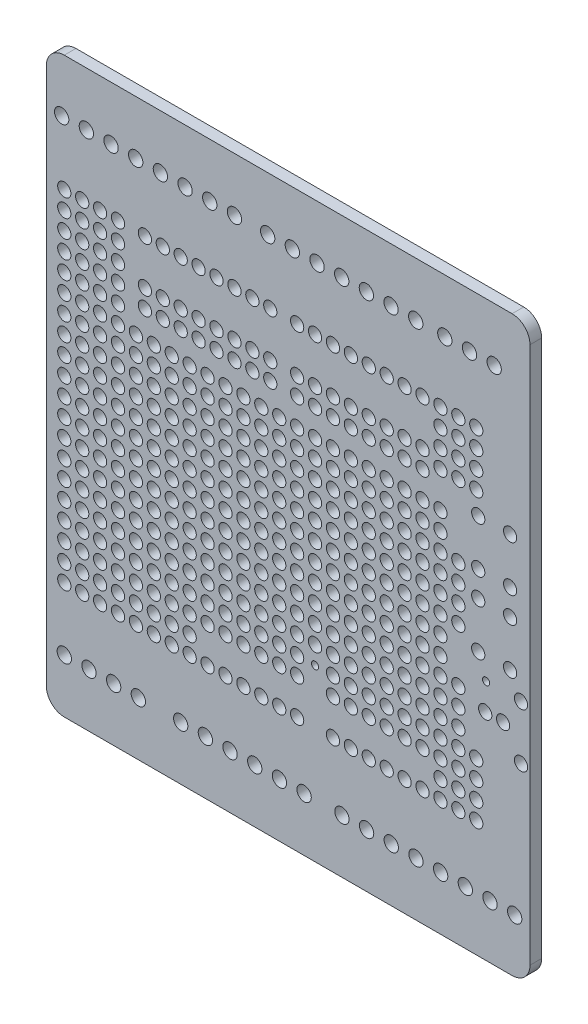
from build123d import *

# Parameters (mm, degrees)
MODEL_R             = 1.016
MODEL_R_2           = 0.9398
MODEL_R_3           = 0.508
BOSS_EXTRUDE1_DEPTH = 1.651


with BuildPart() as part:
    # Model → Boss-Extrude1 (new body)
    with BuildSketch(Plane.XY):
        with BuildLine():
            Line((2.54, 0), (66.04, 0))
            ThreePointArc((66.04, 0), (67.836051224, 0.743948776), (68.58, 2.54))
            Line((68.58, 2.54), (68.58, 78.74))
            ThreePointArc((68.58, 78.74), (67.836051224, 80.536051224), (66.04, 81.28))
            Line((66.04, 81.28), (2.54, 81.28))
            ThreePointArc((2.54, 81.28), (0.743948776, 80.536051224), (0, 78.74))
            Line((0, 78.74), (0, 2.54))
            ThreePointArc((0, 2.54), (0.743948776, 0.743948776), (2.54, 0))
        make_face()
        with Locations((45.409993, 7.62)):
            Circle(MODEL_R, mode=Mode.SUBTRACT)
        with Locations((48.9100114, 7.62)):
            Circle(MODEL_R, mode=Mode.SUBTRACT)
        with Locations((52.4100044, 7.62)):
            Circle(MODEL_R, mode=Mode.SUBTRACT)
        with Locations((55.9099974, 7.62)):
            Circle(MODEL_R, mode=Mode.SUBTRACT)
        with Locations((59.4099904, 7.62)):
            Circle(MODEL_R, mode=Mode.SUBTRACT)
        with Locations((62.9100088, 7.62)):
            Circle(MODEL_R, mode=Mode.SUBTRACT)
        with Locations((66.4100018, 7.62)):
            Circle(MODEL_R, mode=Mode.SUBTRACT)
        with Locations((22.549993, 7.62)):
            Circle(MODEL_R, mode=Mode.SUBTRACT)
        with Locations((26.0500114, 7.62)):
            Circle(MODEL_R, mode=Mode.SUBTRACT)
        with Locations((29.5500044, 7.62)):
            Circle(MODEL_R, mode=Mode.SUBTRACT)
        with Locations((33.0499974, 7.62)):
            Circle(MODEL_R, mode=Mode.SUBTRACT)
        with Locations((36.5499904, 7.62)):
            Circle(MODEL_R, mode=Mode.SUBTRACT)
        with Locations((6.039993, 7.62)):
            Circle(MODEL_R, mode=Mode.SUBTRACT)
        with Locations((9.5400114, 7.62)):
            Circle(MODEL_R, mode=Mode.SUBTRACT)
        with Locations((13.0400044, 7.62)):
            Circle(MODEL_R, mode=Mode.SUBTRACT)
        with Locations((52.380007, 73.66)):
            Circle(MODEL_R, mode=Mode.SUBTRACT)
        with Locations((48.8799886, 73.66)):
            Circle(MODEL_R, mode=Mode.SUBTRACT)
        with Locations((45.3799956, 73.66)):
            Circle(MODEL_R, mode=Mode.SUBTRACT)
        with Locations((41.8800026, 73.66)):
            Circle(MODEL_R, mode=Mode.SUBTRACT)
        with Locations((38.3800096, 73.66)):
            Circle(MODEL_R, mode=Mode.SUBTRACT)
        with Locations((34.8799912, 73.66)):
            Circle(MODEL_R, mode=Mode.SUBTRACT)
        with Locations((31.3799982, 73.66)):
            Circle(MODEL_R, mode=Mode.SUBTRACT)
        with Locations((23.170007, 73.66)):
            Circle(MODEL_R, mode=Mode.SUBTRACT)
        with Locations((19.6699886, 73.66)):
            Circle(MODEL_R, mode=Mode.SUBTRACT)
        with Locations((16.1699956, 73.66)):
            Circle(MODEL_R, mode=Mode.SUBTRACT)
        with Locations((12.6700026, 73.66)):
            Circle(MODEL_R, mode=Mode.SUBTRACT)
        with Locations((9.1700096, 73.66)):
            Circle(MODEL_R, mode=Mode.SUBTRACT)
        with Locations((5.6699912, 73.66)):
            Circle(MODEL_R, mode=Mode.SUBTRACT)
        with Locations((2.1699982, 73.66)):
            Circle(MODEL_R, mode=Mode.SUBTRACT)
        with Locations((60.000007, 73.66)):
            Circle(MODEL_R, mode=Mode.SUBTRACT)
        with Locations((62.23, 30.48)):
            Circle(MODEL_R_2, mode=Mode.SUBTRACT)
        with Locations((64.77, 30.48)):
            Circle(MODEL_R_2, mode=Mode.SUBTRACT)
        with Locations((67.31, 26.67)):
            Circle(MODEL_R_2, mode=Mode.SUBTRACT)
        with Locations((67.31, 34.29)):
            Circle(MODEL_R_2, mode=Mode.SUBTRACT)
        with Locations((65.7606, 43.8912)):
            Circle(MODEL_R_2, mode=Mode.SUBTRACT)
        with Locations((65.7606, 37.3888)):
            Circle(MODEL_R_2, mode=Mode.SUBTRACT)
        with Locations((61.2394, 43.8912)):
            Circle(MODEL_R_2, mode=Mode.SUBTRACT)
        with Locations((61.2394, 37.3888)):
            Circle(MODEL_R_2, mode=Mode.SUBTRACT)
        with Locations((65.7606, 54.0512)):
            Circle(MODEL_R_2, mode=Mode.SUBTRACT)
        with Locations((65.7606, 47.5488)):
            Circle(MODEL_R_2, mode=Mode.SUBTRACT)
        with Locations((61.2394, 54.0512)):
            Circle(MODEL_R_2, mode=Mode.SUBTRACT)
        with Locations((61.2394, 47.5488)):
            Circle(MODEL_R_2, mode=Mode.SUBTRACT)
        with Locations((25.4, 16.51)):
            Circle(MODEL_R_2, mode=Mode.SUBTRACT)
        with Locations((27.94, 16.51)):
            Circle(MODEL_R_2, mode=Mode.SUBTRACT)
        with Locations((40.64, 16.51)):
            Circle(MODEL_R_2, mode=Mode.SUBTRACT)
        with Locations((43.18, 16.51)):
            Circle(MODEL_R_2, mode=Mode.SUBTRACT)
        with Locations((45.72, 16.51)):
            Circle(MODEL_R_2, mode=Mode.SUBTRACT)
        with Locations((48.26, 16.51)):
            Circle(MODEL_R_2, mode=Mode.SUBTRACT)
        with Locations((50.8, 16.51)):
            Circle(MODEL_R_2, mode=Mode.SUBTRACT)
        with Locations((53.34, 16.51)):
            Circle(MODEL_R_2, mode=Mode.SUBTRACT)
        with Locations((13.97, 64.77)):
            Circle(MODEL_R_2, mode=Mode.SUBTRACT)
        with Locations((48.26, 64.77)):
            Circle(MODEL_R_2, mode=Mode.SUBTRACT)
        with Locations((45.72, 64.77)):
            Circle(MODEL_R_2, mode=Mode.SUBTRACT)
        with Locations((43.18, 64.77)):
            Circle(MODEL_R_2, mode=Mode.SUBTRACT)
        with Locations((40.64, 64.77)):
            Circle(MODEL_R_2, mode=Mode.SUBTRACT)
        with Locations((38.1, 64.77)):
            Circle(MODEL_R_2, mode=Mode.SUBTRACT)
        with Locations((35.56, 64.77)):
            Circle(MODEL_R_2, mode=Mode.SUBTRACT)
        with Locations((31.75, 64.77)):
            Circle(MODEL_R_2, mode=Mode.SUBTRACT)
        with Locations((29.21, 64.77)):
            Circle(MODEL_R_2, mode=Mode.SUBTRACT)
        with Locations((26.67, 64.77)):
            Circle(MODEL_R_2, mode=Mode.SUBTRACT)
        with Locations((24.13, 64.77)):
            Circle(MODEL_R_2, mode=Mode.SUBTRACT)
        with Locations((21.59, 64.77)):
            Circle(MODEL_R_2, mode=Mode.SUBTRACT)
        with Locations((19.05, 64.77)):
            Circle(MODEL_R_2, mode=Mode.SUBTRACT)
        with Locations((30.48, 16.51)):
            Circle(MODEL_R_2, mode=Mode.SUBTRACT)
        with Locations((33.02, 16.51)):
            Circle(MODEL_R_2, mode=Mode.SUBTRACT)
        with Locations((16.51, 64.77)):
            Circle(MODEL_R_2, mode=Mode.SUBTRACT)
        with Locations((22.86, 16.51)):
            Circle(MODEL_R_2, mode=Mode.SUBTRACT)
        with Locations((53.34, 64.77)):
            Circle(MODEL_R_2, mode=Mode.SUBTRACT)
        with Locations((50.8, 64.77)):
            Circle(MODEL_R_2, mode=Mode.SUBTRACT)
        with Locations((35.56, 16.51)):
            Circle(MODEL_R_2, mode=Mode.SUBTRACT)
        with Locations((25.4, 24.13)):
            Circle(MODEL_R_2, mode=Mode.SUBTRACT)
        with Locations((25.4, 21.59)):
            Circle(MODEL_R_2, mode=Mode.SUBTRACT)
        with Locations((45.72, 34.29)):
            Circle(MODEL_R_2, mode=Mode.SUBTRACT)
        with Locations((48.26, 34.29)):
            Circle(MODEL_R_2, mode=Mode.SUBTRACT)
        with Locations((50.8, 34.29)):
            Circle(MODEL_R_2, mode=Mode.SUBTRACT)
        with Locations((53.34, 34.29)):
            Circle(MODEL_R_2, mode=Mode.SUBTRACT)
        with Locations((55.88, 34.29)):
            Circle(MODEL_R_2, mode=Mode.SUBTRACT)
        with Locations((43.18, 34.29)):
            Circle(MODEL_R_2, mode=Mode.SUBTRACT)
        with Locations((40.64, 34.29)):
            Circle(MODEL_R_2, mode=Mode.SUBTRACT)
        with Locations((38.1, 34.29)):
            Circle(MODEL_R_2, mode=Mode.SUBTRACT)
        with Locations((35.56, 34.29)):
            Circle(MODEL_R_2, mode=Mode.SUBTRACT)
        with Locations((33.02, 34.29)):
            Circle(MODEL_R_2, mode=Mode.SUBTRACT)
        with Locations((30.48, 34.29)):
            Circle(MODEL_R_2, mode=Mode.SUBTRACT)
        with Locations((27.94, 34.29)):
            Circle(MODEL_R_2, mode=Mode.SUBTRACT)
        with Locations((25.4, 34.29)):
            Circle(MODEL_R_2, mode=Mode.SUBTRACT)
        with Locations((22.86, 34.29)):
            Circle(MODEL_R_2, mode=Mode.SUBTRACT)
        with Locations((17.78, 34.29)):
            Circle(MODEL_R_2, mode=Mode.SUBTRACT)
        with Locations((20.32, 34.29)):
            Circle(MODEL_R_2, mode=Mode.SUBTRACT)
        with Locations((27.94, 24.13)):
            Circle(MODEL_R_2, mode=Mode.SUBTRACT)
        with Locations((45.72, 49.53)):
            Circle(MODEL_R_2, mode=Mode.SUBTRACT)
        with Locations((48.26, 49.53)):
            Circle(MODEL_R_2, mode=Mode.SUBTRACT)
        with Locations((50.8, 49.53)):
            Circle(MODEL_R_2, mode=Mode.SUBTRACT)
        with Locations((53.34, 49.53)):
            Circle(MODEL_R_2, mode=Mode.SUBTRACT)
        with Locations((55.88, 49.53)):
            Circle(MODEL_R_2, mode=Mode.SUBTRACT)
        with Locations((43.18, 49.53)):
            Circle(MODEL_R_2, mode=Mode.SUBTRACT)
        with Locations((40.64, 49.53)):
            Circle(MODEL_R_2, mode=Mode.SUBTRACT)
        with Locations((38.1, 49.53)):
            Circle(MODEL_R_2, mode=Mode.SUBTRACT)
        with Locations((35.56, 49.53)):
            Circle(MODEL_R_2, mode=Mode.SUBTRACT)
        with Locations((33.02, 49.53)):
            Circle(MODEL_R_2, mode=Mode.SUBTRACT)
        with Locations((30.48, 49.53)):
            Circle(MODEL_R_2, mode=Mode.SUBTRACT)
        with Locations((27.94, 49.53)):
            Circle(MODEL_R_2, mode=Mode.SUBTRACT)
        with Locations((25.4, 49.53)):
            Circle(MODEL_R_2, mode=Mode.SUBTRACT)
        with Locations((22.86, 49.53)):
            Circle(MODEL_R_2, mode=Mode.SUBTRACT)
        with Locations((17.78, 49.53)):
            Circle(MODEL_R_2, mode=Mode.SUBTRACT)
        with Locations((20.32, 49.53)):
            Circle(MODEL_R_2, mode=Mode.SUBTRACT)
        with Locations((15.24, 49.53)):
            Circle(MODEL_R_2, mode=Mode.SUBTRACT)
        with Locations((12.7, 49.53)):
            Circle(MODEL_R_2, mode=Mode.SUBTRACT)
        with Locations((10.16, 49.53)):
            Circle(MODEL_R_2, mode=Mode.SUBTRACT)
        with Locations((7.62, 49.53)):
            Circle(MODEL_R_2, mode=Mode.SUBTRACT)
        with Locations((5.08, 49.53)):
            Circle(MODEL_R_2, mode=Mode.SUBTRACT)
        with Locations((2.54, 49.53)):
            Circle(MODEL_R_2, mode=Mode.SUBTRACT)
        with Locations((27.94, 21.59)):
            Circle(MODEL_R_2, mode=Mode.SUBTRACT)
        with Locations((40.64, 21.59)):
            Circle(MODEL_R_2, mode=Mode.SUBTRACT)
        with Locations((40.64, 24.13)):
            Circle(MODEL_R_2, mode=Mode.SUBTRACT)
        with Locations((43.18, 24.13)):
            Circle(MODEL_R_2, mode=Mode.SUBTRACT)
        with Locations((43.18, 21.59)):
            Circle(MODEL_R_2, mode=Mode.SUBTRACT)
        with Locations((45.72, 21.59)):
            Circle(MODEL_R_2, mode=Mode.SUBTRACT)
        with Locations((45.72, 24.13)):
            Circle(MODEL_R_2, mode=Mode.SUBTRACT)
        with Locations((48.26, 24.13)):
            Circle(MODEL_R_2, mode=Mode.SUBTRACT)
        with Locations((48.26, 21.59)):
            Circle(MODEL_R_2, mode=Mode.SUBTRACT)
        with Locations((50.8, 24.13)):
            Circle(MODEL_R_2, mode=Mode.SUBTRACT)
        with Locations((50.8, 21.59)):
            Circle(MODEL_R_2, mode=Mode.SUBTRACT)
        with Locations((53.34, 24.13)):
            Circle(MODEL_R_2, mode=Mode.SUBTRACT)
        with Locations((53.34, 21.59)):
            Circle(MODEL_R_2, mode=Mode.SUBTRACT)
        with Locations((13.97, 55.88)):
            Circle(MODEL_R_2, mode=Mode.SUBTRACT)
        with Locations((13.97, 58.42)):
            Circle(MODEL_R_2, mode=Mode.SUBTRACT)
        with Locations((5.08, 29.21)):
            Circle(MODEL_R_2, mode=Mode.SUBTRACT)
        with Locations((5.08, 31.75)):
            Circle(MODEL_R_2, mode=Mode.SUBTRACT)
        with Locations((5.08, 26.67)):
            Circle(MODEL_R_2, mode=Mode.SUBTRACT)
        with Locations((7.62, 31.75)):
            Circle(MODEL_R_2, mode=Mode.SUBTRACT)
        with Locations((7.62, 26.67)):
            Circle(MODEL_R_2, mode=Mode.SUBTRACT)
        with Locations((7.62, 29.21)):
            Circle(MODEL_R_2, mode=Mode.SUBTRACT)
        with Locations((10.16, 29.21)):
            Circle(MODEL_R_2, mode=Mode.SUBTRACT)
        with Locations((10.16, 31.75)):
            Circle(MODEL_R_2, mode=Mode.SUBTRACT)
        with Locations((10.16, 26.67)):
            Circle(MODEL_R_2, mode=Mode.SUBTRACT)
        with Locations((12.7, 31.75)):
            Circle(MODEL_R_2, mode=Mode.SUBTRACT)
        with Locations((12.7, 29.21)):
            Circle(MODEL_R_2, mode=Mode.SUBTRACT)
        with Locations((12.7, 26.67)):
            Circle(MODEL_R_2, mode=Mode.SUBTRACT)
        with Locations((15.24, 26.67)):
            Circle(MODEL_R_2, mode=Mode.SUBTRACT)
        with Locations((15.24, 29.21)):
            Circle(MODEL_R_2, mode=Mode.SUBTRACT)
        with Locations((15.24, 31.75)):
            Circle(MODEL_R_2, mode=Mode.SUBTRACT)
        with Locations((17.78, 26.67)):
            Circle(MODEL_R_2, mode=Mode.SUBTRACT)
        with Locations((17.78, 29.21)):
            Circle(MODEL_R_2, mode=Mode.SUBTRACT)
        with Locations((17.78, 31.75)):
            Circle(MODEL_R_2, mode=Mode.SUBTRACT)
        with Locations((20.32, 26.67)):
            Circle(MODEL_R_2, mode=Mode.SUBTRACT)
        with Locations((20.32, 29.21)):
            Circle(MODEL_R_2, mode=Mode.SUBTRACT)
        with Locations((20.32, 31.75)):
            Circle(MODEL_R_2, mode=Mode.SUBTRACT)
        with Locations((22.86, 26.67)):
            Circle(MODEL_R_2, mode=Mode.SUBTRACT)
        with Locations((22.86, 29.21)):
            Circle(MODEL_R_2, mode=Mode.SUBTRACT)
        with Locations((22.86, 31.75)):
            Circle(MODEL_R_2, mode=Mode.SUBTRACT)
        with Locations((25.4, 26.67)):
            Circle(MODEL_R_2, mode=Mode.SUBTRACT)
        with Locations((25.4, 29.21)):
            Circle(MODEL_R_2, mode=Mode.SUBTRACT)
        with Locations((25.4, 31.75)):
            Circle(MODEL_R_2, mode=Mode.SUBTRACT)
        with Locations((27.94, 26.67)):
            Circle(MODEL_R_2, mode=Mode.SUBTRACT)
        with Locations((27.94, 29.21)):
            Circle(MODEL_R_2, mode=Mode.SUBTRACT)
        with Locations((27.94, 31.75)):
            Circle(MODEL_R_2, mode=Mode.SUBTRACT)
        with Locations((30.48, 26.67)):
            Circle(MODEL_R_2, mode=Mode.SUBTRACT)
        with Locations((30.48, 29.21)):
            Circle(MODEL_R_2, mode=Mode.SUBTRACT)
        with Locations((30.48, 31.75)):
            Circle(MODEL_R_2, mode=Mode.SUBTRACT)
        with Locations((33.02, 26.67)):
            Circle(MODEL_R_2, mode=Mode.SUBTRACT)
        with Locations((33.02, 29.21)):
            Circle(MODEL_R_2, mode=Mode.SUBTRACT)
        with Locations((33.02, 31.75)):
            Circle(MODEL_R_2, mode=Mode.SUBTRACT)
        with Locations((35.56, 26.67)):
            Circle(MODEL_R_2, mode=Mode.SUBTRACT)
        with Locations((35.56, 29.21)):
            Circle(MODEL_R_2, mode=Mode.SUBTRACT)
        with Locations((35.56, 31.75)):
            Circle(MODEL_R_2, mode=Mode.SUBTRACT)
        with Locations((38.1, 26.67)):
            Circle(MODEL_R_2, mode=Mode.SUBTRACT)
        with Locations((38.1, 29.21)):
            Circle(MODEL_R_2, mode=Mode.SUBTRACT)
        with Locations((38.1, 31.75)):
            Circle(MODEL_R_2, mode=Mode.SUBTRACT)
        with Locations((40.64, 26.67)):
            Circle(MODEL_R_2, mode=Mode.SUBTRACT)
        with Locations((40.64, 29.21)):
            Circle(MODEL_R_2, mode=Mode.SUBTRACT)
        with Locations((40.64, 31.75)):
            Circle(MODEL_R_2, mode=Mode.SUBTRACT)
        with Locations((43.18, 26.67)):
            Circle(MODEL_R_2, mode=Mode.SUBTRACT)
        with Locations((43.18, 29.21)):
            Circle(MODEL_R_2, mode=Mode.SUBTRACT)
        with Locations((43.18, 31.75)):
            Circle(MODEL_R_2, mode=Mode.SUBTRACT)
        with Locations((45.72, 26.67)):
            Circle(MODEL_R_2, mode=Mode.SUBTRACT)
        with Locations((45.72, 29.21)):
            Circle(MODEL_R_2, mode=Mode.SUBTRACT)
        with Locations((45.72, 31.75)):
            Circle(MODEL_R_2, mode=Mode.SUBTRACT)
        with Locations((48.26, 26.67)):
            Circle(MODEL_R_2, mode=Mode.SUBTRACT)
        with Locations((48.26, 29.21)):
            Circle(MODEL_R_2, mode=Mode.SUBTRACT)
        with Locations((48.26, 31.75)):
            Circle(MODEL_R_2, mode=Mode.SUBTRACT)
        with Locations((50.8, 26.67)):
            Circle(MODEL_R_2, mode=Mode.SUBTRACT)
        with Locations((50.8, 29.21)):
            Circle(MODEL_R_2, mode=Mode.SUBTRACT)
        with Locations((50.8, 31.75)):
            Circle(MODEL_R_2, mode=Mode.SUBTRACT)
        with Locations((53.34, 26.67)):
            Circle(MODEL_R_2, mode=Mode.SUBTRACT)
        with Locations((53.34, 29.21)):
            Circle(MODEL_R_2, mode=Mode.SUBTRACT)
        with Locations((53.34, 31.75)):
            Circle(MODEL_R_2, mode=Mode.SUBTRACT)
        with Locations((55.88, 29.21)):
            Circle(MODEL_R_2, mode=Mode.SUBTRACT)
        with Locations((15.24, 46.99)):
            Circle(MODEL_R_2, mode=Mode.SUBTRACT)
        with Locations((12.7, 46.99)):
            Circle(MODEL_R_2, mode=Mode.SUBTRACT)
        with Locations((15.24, 44.45)):
            Circle(MODEL_R_2, mode=Mode.SUBTRACT)
        with Locations((15.24, 41.91)):
            Circle(MODEL_R_2, mode=Mode.SUBTRACT)
        with Locations((12.7, 44.45)):
            Circle(MODEL_R_2, mode=Mode.SUBTRACT)
        with Locations((10.16, 46.99)):
            Circle(MODEL_R_2, mode=Mode.SUBTRACT)
        with Locations((7.62, 46.99)):
            Circle(MODEL_R_2, mode=Mode.SUBTRACT)
        with Locations((10.16, 44.45)):
            Circle(MODEL_R_2, mode=Mode.SUBTRACT)
        with Locations((12.7, 41.91)):
            Circle(MODEL_R_2, mode=Mode.SUBTRACT)
        with Locations((15.24, 39.37)):
            Circle(MODEL_R_2, mode=Mode.SUBTRACT)
        with Locations((15.24, 36.83)):
            Circle(MODEL_R_2, mode=Mode.SUBTRACT)
        with Locations((12.7, 39.37)):
            Circle(MODEL_R_2, mode=Mode.SUBTRACT)
        with Locations((10.16, 41.91)):
            Circle(MODEL_R_2, mode=Mode.SUBTRACT)
        with Locations((7.62, 44.45)):
            Circle(MODEL_R_2, mode=Mode.SUBTRACT)
        with Locations((5.08, 46.99)):
            Circle(MODEL_R_2, mode=Mode.SUBTRACT)
        with Locations((2.54, 46.99)):
            Circle(MODEL_R_2, mode=Mode.SUBTRACT)
        with Locations((5.08, 44.45)):
            Circle(MODEL_R_2, mode=Mode.SUBTRACT)
        with Locations((7.62, 41.91)):
            Circle(MODEL_R_2, mode=Mode.SUBTRACT)
        with Locations((10.16, 39.37)):
            Circle(MODEL_R_2, mode=Mode.SUBTRACT)
        with Locations((12.7, 36.83)):
            Circle(MODEL_R_2, mode=Mode.SUBTRACT)
        with Locations((15.24, 34.29)):
            Circle(MODEL_R_2, mode=Mode.SUBTRACT)
        with Locations((12.7, 34.29)):
            Circle(MODEL_R_2, mode=Mode.SUBTRACT)
        with Locations((10.16, 36.83)):
            Circle(MODEL_R_2, mode=Mode.SUBTRACT)
        with Locations((7.62, 39.37)):
            Circle(MODEL_R_2, mode=Mode.SUBTRACT)
        with Locations((2.54, 44.45)):
            Circle(MODEL_R_2, mode=Mode.SUBTRACT)
        with Locations((5.08, 41.91)):
            Circle(MODEL_R_2, mode=Mode.SUBTRACT)
        with Locations((2.54, 41.91)):
            Circle(MODEL_R_2, mode=Mode.SUBTRACT)
        with Locations((5.08, 39.37)):
            Circle(MODEL_R_2, mode=Mode.SUBTRACT)
        with Locations((7.62, 36.83)):
            Circle(MODEL_R_2, mode=Mode.SUBTRACT)
        with Locations((10.16, 34.29)):
            Circle(MODEL_R_2, mode=Mode.SUBTRACT)
        with Locations((7.62, 34.29)):
            Circle(MODEL_R_2, mode=Mode.SUBTRACT)
        with Locations((2.54, 39.37)):
            Circle(MODEL_R_2, mode=Mode.SUBTRACT)
        with Locations((5.08, 36.83)):
            Circle(MODEL_R_2, mode=Mode.SUBTRACT)
        with Locations((2.54, 36.83)):
            Circle(MODEL_R_2, mode=Mode.SUBTRACT)
        with Locations((5.08, 34.29)):
            Circle(MODEL_R_2, mode=Mode.SUBTRACT)
        with Locations((2.54, 34.29)):
            Circle(MODEL_R_2, mode=Mode.SUBTRACT)
        with Locations((53.34, 58.42)):
            Circle(MODEL_R_2, mode=Mode.SUBTRACT)
        with Locations((53.34, 55.88)):
            Circle(MODEL_R_2, mode=Mode.SUBTRACT)
        with Locations((50.8, 58.42)):
            Circle(MODEL_R_2, mode=Mode.SUBTRACT)
        with Locations((50.8, 55.88)):
            Circle(MODEL_R_2, mode=Mode.SUBTRACT)
        with Locations((48.26, 58.42)):
            Circle(MODEL_R_2, mode=Mode.SUBTRACT)
        with Locations((48.26, 55.88)):
            Circle(MODEL_R_2, mode=Mode.SUBTRACT)
        with Locations((45.72, 58.42)):
            Circle(MODEL_R_2, mode=Mode.SUBTRACT)
        with Locations((45.72, 55.88)):
            Circle(MODEL_R_2, mode=Mode.SUBTRACT)
        with Locations((43.18, 58.42)):
            Circle(MODEL_R_2, mode=Mode.SUBTRACT)
        with Locations((43.18, 55.88)):
            Circle(MODEL_R_2, mode=Mode.SUBTRACT)
        with Locations((40.64, 58.42)):
            Circle(MODEL_R_2, mode=Mode.SUBTRACT)
        with Locations((40.64, 55.88)):
            Circle(MODEL_R_2, mode=Mode.SUBTRACT)
        with Locations((38.1, 58.42)):
            Circle(MODEL_R_2, mode=Mode.SUBTRACT)
        with Locations((38.1, 55.88)):
            Circle(MODEL_R_2, mode=Mode.SUBTRACT)
        with Locations((35.56, 58.42)):
            Circle(MODEL_R_2, mode=Mode.SUBTRACT)
        with Locations((35.56, 55.88)):
            Circle(MODEL_R_2, mode=Mode.SUBTRACT)
        with Locations((31.75, 58.42)):
            Circle(MODEL_R_2, mode=Mode.SUBTRACT)
        with Locations((31.75, 55.88)):
            Circle(MODEL_R_2, mode=Mode.SUBTRACT)
        with Locations((29.21, 58.42)):
            Circle(MODEL_R_2, mode=Mode.SUBTRACT)
        with Locations((29.21, 55.88)):
            Circle(MODEL_R_2, mode=Mode.SUBTRACT)
        with Locations((26.67, 58.42)):
            Circle(MODEL_R_2, mode=Mode.SUBTRACT)
        with Locations((26.67, 55.88)):
            Circle(MODEL_R_2, mode=Mode.SUBTRACT)
        with Locations((24.13, 58.42)):
            Circle(MODEL_R_2, mode=Mode.SUBTRACT)
        with Locations((24.13, 55.88)):
            Circle(MODEL_R_2, mode=Mode.SUBTRACT)
        with Locations((21.59, 58.42)):
            Circle(MODEL_R_2, mode=Mode.SUBTRACT)
        with Locations((21.59, 55.88)):
            Circle(MODEL_R_2, mode=Mode.SUBTRACT)
        with Locations((19.05, 58.42)):
            Circle(MODEL_R_2, mode=Mode.SUBTRACT)
        with Locations((19.05, 55.88)):
            Circle(MODEL_R_2, mode=Mode.SUBTRACT)
        with Locations((16.51, 58.42)):
            Circle(MODEL_R_2, mode=Mode.SUBTRACT)
        with Locations((16.51, 55.88)):
            Circle(MODEL_R_2, mode=Mode.SUBTRACT)
        with Locations((33.02, 24.13)):
            Circle(MODEL_R_2, mode=Mode.SUBTRACT)
        with Locations((55.88, 52.07)):
            Circle(MODEL_R_2, mode=Mode.SUBTRACT)
        with Locations((53.34, 52.07)):
            Circle(MODEL_R_2, mode=Mode.SUBTRACT)
        with Locations((50.8, 52.07)):
            Circle(MODEL_R_2, mode=Mode.SUBTRACT)
        with Locations((48.26, 52.07)):
            Circle(MODEL_R_2, mode=Mode.SUBTRACT)
        with Locations((45.72, 52.07)):
            Circle(MODEL_R_2, mode=Mode.SUBTRACT)
        with Locations((43.18, 52.07)):
            Circle(MODEL_R_2, mode=Mode.SUBTRACT)
        with Locations((40.64, 52.07)):
            Circle(MODEL_R_2, mode=Mode.SUBTRACT)
        with Locations((38.1, 52.07)):
            Circle(MODEL_R_2, mode=Mode.SUBTRACT)
        with Locations((35.56, 52.07)):
            Circle(MODEL_R_2, mode=Mode.SUBTRACT)
        with Locations((33.02, 52.07)):
            Circle(MODEL_R_2, mode=Mode.SUBTRACT)
        with Locations((30.48, 52.07)):
            Circle(MODEL_R_2, mode=Mode.SUBTRACT)
        with Locations((27.94, 52.07)):
            Circle(MODEL_R_2, mode=Mode.SUBTRACT)
        with Locations((25.4, 52.07)):
            Circle(MODEL_R_2, mode=Mode.SUBTRACT)
        with Locations((22.86, 52.07)):
            Circle(MODEL_R_2, mode=Mode.SUBTRACT)
        with Locations((20.32, 52.07)):
            Circle(MODEL_R_2, mode=Mode.SUBTRACT)
        with Locations((17.78, 52.07)):
            Circle(MODEL_R_2, mode=Mode.SUBTRACT)
        with Locations((15.24, 52.07)):
            Circle(MODEL_R_2, mode=Mode.SUBTRACT)
        with Locations((12.7, 52.07)):
            Circle(MODEL_R_2, mode=Mode.SUBTRACT)
        with Locations((10.16, 52.07)):
            Circle(MODEL_R_2, mode=Mode.SUBTRACT)
        with Locations((7.62, 52.07)):
            Circle(MODEL_R_2, mode=Mode.SUBTRACT)
        with Locations((5.08, 52.07)):
            Circle(MODEL_R_2, mode=Mode.SUBTRACT)
        with Locations((2.54, 52.07)):
            Circle(MODEL_R_2, mode=Mode.SUBTRACT)
        with Locations((30.48, 21.59)):
            Circle(MODEL_R_2, mode=Mode.SUBTRACT)
        with Locations((30.48, 24.13)):
            Circle(MODEL_R_2, mode=Mode.SUBTRACT)
        with Locations((33.02, 21.59)):
            Circle(MODEL_R_2, mode=Mode.SUBTRACT)
        with Locations((55.88, 36.83)):
            Circle(MODEL_R_2, mode=Mode.SUBTRACT)
        with Locations((53.34, 36.83)):
            Circle(MODEL_R_2, mode=Mode.SUBTRACT)
        with Locations((50.8, 36.83)):
            Circle(MODEL_R_2, mode=Mode.SUBTRACT)
        with Locations((48.26, 36.83)):
            Circle(MODEL_R_2, mode=Mode.SUBTRACT)
        with Locations((45.72, 36.83)):
            Circle(MODEL_R_2, mode=Mode.SUBTRACT)
        with Locations((43.18, 36.83)):
            Circle(MODEL_R_2, mode=Mode.SUBTRACT)
        with Locations((40.64, 36.83)):
            Circle(MODEL_R_2, mode=Mode.SUBTRACT)
        with Locations((38.1, 36.83)):
            Circle(MODEL_R_2, mode=Mode.SUBTRACT)
        with Locations((35.56, 36.83)):
            Circle(MODEL_R_2, mode=Mode.SUBTRACT)
        with Locations((33.02, 36.83)):
            Circle(MODEL_R_2, mode=Mode.SUBTRACT)
        with Locations((30.48, 36.83)):
            Circle(MODEL_R_2, mode=Mode.SUBTRACT)
        with Locations((27.94, 36.83)):
            Circle(MODEL_R_2, mode=Mode.SUBTRACT)
        with Locations((25.4, 36.83)):
            Circle(MODEL_R_2, mode=Mode.SUBTRACT)
        with Locations((22.86, 36.83)):
            Circle(MODEL_R_2, mode=Mode.SUBTRACT)
        with Locations((20.32, 36.83)):
            Circle(MODEL_R_2, mode=Mode.SUBTRACT)
        with Locations((17.78, 36.83)):
            Circle(MODEL_R_2, mode=Mode.SUBTRACT)
        with Locations((55.88, 31.75)):
            Circle(MODEL_R_2, mode=Mode.SUBTRACT)
        with Locations((55.88, 26.67)):
            Circle(MODEL_R_2, mode=Mode.SUBTRACT)
        with Locations((2.54, 16.51)):
            Circle(MODEL_R_2, mode=Mode.SUBTRACT)
        with Locations((2.54, 19.05)):
            Circle(MODEL_R_2, mode=Mode.SUBTRACT)
        with Locations((2.54, 24.13)):
            Circle(MODEL_R_2, mode=Mode.SUBTRACT)
        with Locations((2.54, 21.59)):
            Circle(MODEL_R_2, mode=Mode.SUBTRACT)
        with Locations((5.08, 24.13)):
            Circle(MODEL_R_2, mode=Mode.SUBTRACT)
        with Locations((5.08, 59.69)):
            Circle(MODEL_R_2, mode=Mode.SUBTRACT)
        with Locations((5.08, 57.15)):
            Circle(MODEL_R_2, mode=Mode.SUBTRACT)
        with Locations((7.62, 57.15)):
            Circle(MODEL_R_2, mode=Mode.SUBTRACT)
        with Locations((7.62, 59.69)):
            Circle(MODEL_R_2, mode=Mode.SUBTRACT)
        with Locations((10.16, 59.69)):
            Circle(MODEL_R_2, mode=Mode.SUBTRACT)
        with Locations((10.16, 57.15)):
            Circle(MODEL_R_2, mode=Mode.SUBTRACT)
        with Locations((7.62, 24.13)):
            Circle(MODEL_R_2, mode=Mode.SUBTRACT)
        with Locations((10.16, 24.13)):
            Circle(MODEL_R_2, mode=Mode.SUBTRACT)
        with Locations((12.7, 24.13)):
            Circle(MODEL_R_2, mode=Mode.SUBTRACT)
        with Locations((15.24, 24.13)):
            Circle(MODEL_R_2, mode=Mode.SUBTRACT)
        with Locations((17.78, 24.13)):
            Circle(MODEL_R_2, mode=Mode.SUBTRACT)
        with Locations((20.32, 24.13)):
            Circle(MODEL_R_2, mode=Mode.SUBTRACT)
        with Locations((5.08, 21.59)):
            Circle(MODEL_R_2, mode=Mode.SUBTRACT)
        with Locations((7.62, 21.59)):
            Circle(MODEL_R_2, mode=Mode.SUBTRACT)
        with Locations((10.16, 21.59)):
            Circle(MODEL_R_2, mode=Mode.SUBTRACT)
        with Locations((12.7, 21.59)):
            Circle(MODEL_R_2, mode=Mode.SUBTRACT)
        with Locations((15.24, 21.59)):
            Circle(MODEL_R_2, mode=Mode.SUBTRACT)
        with Locations((17.78, 21.59)):
            Circle(MODEL_R_2, mode=Mode.SUBTRACT)
        with Locations((20.32, 21.59)):
            Circle(MODEL_R_2, mode=Mode.SUBTRACT)
        with Locations((55.88, 24.13)):
            Circle(MODEL_R_2, mode=Mode.SUBTRACT)
        with Locations((58.42, 24.13)):
            Circle(MODEL_R_2, mode=Mode.SUBTRACT)
        with Locations((60.96, 24.13)):
            Circle(MODEL_R_2, mode=Mode.SUBTRACT)
        with Locations((55.88, 21.59)):
            Circle(MODEL_R_2, mode=Mode.SUBTRACT)
        with Locations((58.42, 21.59)):
            Circle(MODEL_R_2, mode=Mode.SUBTRACT)
        with Locations((60.96, 21.59)):
            Circle(MODEL_R_2, mode=Mode.SUBTRACT)
        with Locations((55.88, 59.69)):
            Circle(MODEL_R_2, mode=Mode.SUBTRACT)
        with Locations((58.42, 59.69)):
            Circle(MODEL_R_2, mode=Mode.SUBTRACT)
        with Locations((60.96, 59.69)):
            Circle(MODEL_R_2, mode=Mode.SUBTRACT)
        with Locations((55.88, 57.15)):
            Circle(MODEL_R_2, mode=Mode.SUBTRACT)
        with Locations((58.42, 57.15)):
            Circle(MODEL_R_2, mode=Mode.SUBTRACT)
        with Locations((60.96, 57.15)):
            Circle(MODEL_R_2, mode=Mode.SUBTRACT)
        with Locations((2.54, 26.67)):
            Circle(MODEL_R_2, mode=Mode.SUBTRACT)
        with Locations((58.42, 26.67)):
            Circle(MODEL_R_2, mode=Mode.SUBTRACT)
        with Locations((2.54, 29.21)):
            Circle(MODEL_R_2, mode=Mode.SUBTRACT)
        with Locations((58.42, 29.21)):
            Circle(MODEL_R_2, mode=Mode.SUBTRACT)
        with Locations((2.54, 31.75)):
            Circle(MODEL_R_2, mode=Mode.SUBTRACT)
        with Locations((58.42, 31.75)):
            Circle(MODEL_R_2, mode=Mode.SUBTRACT)
        with Locations((17.78, 39.37)):
            Circle(MODEL_R_2, mode=Mode.SUBTRACT)
        with Locations((20.32, 39.37)):
            Circle(MODEL_R_2, mode=Mode.SUBTRACT)
        with Locations((22.86, 39.37)):
            Circle(MODEL_R_2, mode=Mode.SUBTRACT)
        with Locations((25.4, 39.37)):
            Circle(MODEL_R_2, mode=Mode.SUBTRACT)
        with Locations((27.94, 39.37)):
            Circle(MODEL_R_2, mode=Mode.SUBTRACT)
        with Locations((30.48, 39.37)):
            Circle(MODEL_R_2, mode=Mode.SUBTRACT)
        with Locations((33.02, 39.37)):
            Circle(MODEL_R_2, mode=Mode.SUBTRACT)
        with Locations((35.56, 39.37)):
            Circle(MODEL_R_2, mode=Mode.SUBTRACT)
        with Locations((38.1, 39.37)):
            Circle(MODEL_R_2, mode=Mode.SUBTRACT)
        with Locations((40.64, 39.37)):
            Circle(MODEL_R_2, mode=Mode.SUBTRACT)
        with Locations((43.18, 39.37)):
            Circle(MODEL_R_2, mode=Mode.SUBTRACT)
        with Locations((45.72, 39.37)):
            Circle(MODEL_R_2, mode=Mode.SUBTRACT)
        with Locations((48.26, 39.37)):
            Circle(MODEL_R_2, mode=Mode.SUBTRACT)
        with Locations((50.8, 39.37)):
            Circle(MODEL_R_2, mode=Mode.SUBTRACT)
        with Locations((53.34, 39.37)):
            Circle(MODEL_R_2, mode=Mode.SUBTRACT)
        with Locations((55.88, 39.37)):
            Circle(MODEL_R_2, mode=Mode.SUBTRACT)
        with Locations((58.42, 39.37)):
            Circle(MODEL_R_2, mode=Mode.SUBTRACT)
        with Locations((17.78, 41.91)):
            Circle(MODEL_R_2, mode=Mode.SUBTRACT)
        with Locations((20.32, 41.91)):
            Circle(MODEL_R_2, mode=Mode.SUBTRACT)
        with Locations((22.86, 41.91)):
            Circle(MODEL_R_2, mode=Mode.SUBTRACT)
        with Locations((25.4, 41.91)):
            Circle(MODEL_R_2, mode=Mode.SUBTRACT)
        with Locations((27.94, 41.91)):
            Circle(MODEL_R_2, mode=Mode.SUBTRACT)
        with Locations((30.48, 41.91)):
            Circle(MODEL_R_2, mode=Mode.SUBTRACT)
        with Locations((33.02, 41.91)):
            Circle(MODEL_R_2, mode=Mode.SUBTRACT)
        with Locations((35.56, 41.91)):
            Circle(MODEL_R_2, mode=Mode.SUBTRACT)
        with Locations((38.1, 41.91)):
            Circle(MODEL_R_2, mode=Mode.SUBTRACT)
        with Locations((40.64, 41.91)):
            Circle(MODEL_R_2, mode=Mode.SUBTRACT)
        with Locations((43.18, 41.91)):
            Circle(MODEL_R_2, mode=Mode.SUBTRACT)
        with Locations((45.72, 41.91)):
            Circle(MODEL_R_2, mode=Mode.SUBTRACT)
        with Locations((48.26, 41.91)):
            Circle(MODEL_R_2, mode=Mode.SUBTRACT)
        with Locations((50.8, 41.91)):
            Circle(MODEL_R_2, mode=Mode.SUBTRACT)
        with Locations((53.34, 41.91)):
            Circle(MODEL_R_2, mode=Mode.SUBTRACT)
        with Locations((55.88, 41.91)):
            Circle(MODEL_R_2, mode=Mode.SUBTRACT)
        with Locations((58.42, 41.91)):
            Circle(MODEL_R_2, mode=Mode.SUBTRACT)
        with Locations((17.78, 44.45)):
            Circle(MODEL_R_2, mode=Mode.SUBTRACT)
        with Locations((20.32, 44.45)):
            Circle(MODEL_R_2, mode=Mode.SUBTRACT)
        with Locations((22.86, 44.45)):
            Circle(MODEL_R_2, mode=Mode.SUBTRACT)
        with Locations((25.4, 44.45)):
            Circle(MODEL_R_2, mode=Mode.SUBTRACT)
        with Locations((27.94, 44.45)):
            Circle(MODEL_R_2, mode=Mode.SUBTRACT)
        with Locations((30.48, 44.45)):
            Circle(MODEL_R_2, mode=Mode.SUBTRACT)
        with Locations((33.02, 44.45)):
            Circle(MODEL_R_2, mode=Mode.SUBTRACT)
        with Locations((35.56, 44.45)):
            Circle(MODEL_R_2, mode=Mode.SUBTRACT)
        with Locations((38.1, 44.45)):
            Circle(MODEL_R_2, mode=Mode.SUBTRACT)
        with Locations((40.64, 44.45)):
            Circle(MODEL_R_2, mode=Mode.SUBTRACT)
        with Locations((43.18, 44.45)):
            Circle(MODEL_R_2, mode=Mode.SUBTRACT)
        with Locations((45.72, 44.45)):
            Circle(MODEL_R_2, mode=Mode.SUBTRACT)
        with Locations((48.26, 44.45)):
            Circle(MODEL_R_2, mode=Mode.SUBTRACT)
        with Locations((50.8, 44.45)):
            Circle(MODEL_R_2, mode=Mode.SUBTRACT)
        with Locations((53.34, 44.45)):
            Circle(MODEL_R_2, mode=Mode.SUBTRACT)
        with Locations((55.88, 44.45)):
            Circle(MODEL_R_2, mode=Mode.SUBTRACT)
        with Locations((58.42, 44.45)):
            Circle(MODEL_R_2, mode=Mode.SUBTRACT)
        with Locations((17.78, 46.99)):
            Circle(MODEL_R_2, mode=Mode.SUBTRACT)
        with Locations((20.32, 46.99)):
            Circle(MODEL_R_2, mode=Mode.SUBTRACT)
        with Locations((22.86, 46.99)):
            Circle(MODEL_R_2, mode=Mode.SUBTRACT)
        with Locations((25.4, 46.99)):
            Circle(MODEL_R_2, mode=Mode.SUBTRACT)
        with Locations((27.94, 46.99)):
            Circle(MODEL_R_2, mode=Mode.SUBTRACT)
        with Locations((30.48, 46.99)):
            Circle(MODEL_R_2, mode=Mode.SUBTRACT)
        with Locations((33.02, 46.99)):
            Circle(MODEL_R_2, mode=Mode.SUBTRACT)
        with Locations((35.56, 46.99)):
            Circle(MODEL_R_2, mode=Mode.SUBTRACT)
        with Locations((38.1, 46.99)):
            Circle(MODEL_R_2, mode=Mode.SUBTRACT)
        with Locations((40.64, 46.99)):
            Circle(MODEL_R_2, mode=Mode.SUBTRACT)
        with Locations((43.18, 46.99)):
            Circle(MODEL_R_2, mode=Mode.SUBTRACT)
        with Locations((45.72, 46.99)):
            Circle(MODEL_R_2, mode=Mode.SUBTRACT)
        with Locations((48.26, 46.99)):
            Circle(MODEL_R_2, mode=Mode.SUBTRACT)
        with Locations((50.8, 46.99)):
            Circle(MODEL_R_2, mode=Mode.SUBTRACT)
        with Locations((53.34, 46.99)):
            Circle(MODEL_R_2, mode=Mode.SUBTRACT)
        with Locations((55.88, 46.99)):
            Circle(MODEL_R_2, mode=Mode.SUBTRACT)
        with Locations((58.42, 46.99)):
            Circle(MODEL_R_2, mode=Mode.SUBTRACT)
        with Locations((2.54, 54.61)):
            Circle(MODEL_R_2, mode=Mode.SUBTRACT)
        with Locations((5.08, 54.61)):
            Circle(MODEL_R_2, mode=Mode.SUBTRACT)
        with Locations((7.62, 54.61)):
            Circle(MODEL_R_2, mode=Mode.SUBTRACT)
        with Locations((10.16, 54.61)):
            Circle(MODEL_R_2, mode=Mode.SUBTRACT)
        with Locations((2.54, 57.15)):
            Circle(MODEL_R_2, mode=Mode.SUBTRACT)
        with Locations((2.54, 59.69)):
            Circle(MODEL_R_2, mode=Mode.SUBTRACT)
        with Locations((5.08, 19.05)):
            Circle(MODEL_R_2, mode=Mode.SUBTRACT)
        with Locations((7.62, 19.05)):
            Circle(MODEL_R_2, mode=Mode.SUBTRACT)
        with Locations((10.16, 19.05)):
            Circle(MODEL_R_2, mode=Mode.SUBTRACT)
        with Locations((12.7, 19.05)):
            Circle(MODEL_R_2, mode=Mode.SUBTRACT)
        with Locations((15.24, 19.05)):
            Circle(MODEL_R_2, mode=Mode.SUBTRACT)
        with Locations((17.78, 19.05)):
            Circle(MODEL_R_2, mode=Mode.SUBTRACT)
        with Locations((20.32, 19.05)):
            Circle(MODEL_R_2, mode=Mode.SUBTRACT)
        with Locations((5.08, 16.51)):
            Circle(MODEL_R_2, mode=Mode.SUBTRACT)
        with Locations((7.62, 16.51)):
            Circle(MODEL_R_2, mode=Mode.SUBTRACT)
        with Locations((10.16, 16.51)):
            Circle(MODEL_R_2, mode=Mode.SUBTRACT)
        with Locations((12.7, 16.51)):
            Circle(MODEL_R_2, mode=Mode.SUBTRACT)
        with Locations((15.24, 16.51)):
            Circle(MODEL_R_2, mode=Mode.SUBTRACT)
        with Locations((17.78, 16.51)):
            Circle(MODEL_R_2, mode=Mode.SUBTRACT)
        with Locations((20.32, 16.51)):
            Circle(MODEL_R_2, mode=Mode.SUBTRACT)
        with Locations((2.54, 62.23)):
            Circle(MODEL_R_2, mode=Mode.SUBTRACT)
        with Locations((5.08, 62.23)):
            Circle(MODEL_R_2, mode=Mode.SUBTRACT)
        with Locations((7.62, 62.23)):
            Circle(MODEL_R_2, mode=Mode.SUBTRACT)
        with Locations((55.88, 19.05)):
            Circle(MODEL_R_2, mode=Mode.SUBTRACT)
        with Locations((58.42, 19.05)):
            Circle(MODEL_R_2, mode=Mode.SUBTRACT)
        with Locations((60.96, 19.05)):
            Circle(MODEL_R_2, mode=Mode.SUBTRACT)
        with Locations((10.16, 62.23)):
            Circle(MODEL_R_2, mode=Mode.SUBTRACT)
        with Locations((2.54, 64.77)):
            Circle(MODEL_R_2, mode=Mode.SUBTRACT)
        with Locations((5.08, 64.77)):
            Circle(MODEL_R_2, mode=Mode.SUBTRACT)
        with Locations((7.62, 64.77)):
            Circle(MODEL_R_2, mode=Mode.SUBTRACT)
        with Locations((10.16, 64.77)):
            Circle(MODEL_R_2, mode=Mode.SUBTRACT)
        with Locations((55.88, 16.51)):
            Circle(MODEL_R_2, mode=Mode.SUBTRACT)
        with Locations((58.42, 16.51)):
            Circle(MODEL_R_2, mode=Mode.SUBTRACT)
        with Locations((60.96, 16.51)):
            Circle(MODEL_R_2, mode=Mode.SUBTRACT)
        with Locations((55.88, 62.23)):
            Circle(MODEL_R_2, mode=Mode.SUBTRACT)
        with Locations((58.42, 62.23)):
            Circle(MODEL_R_2, mode=Mode.SUBTRACT)
        with Locations((60.96, 62.23)):
            Circle(MODEL_R_2, mode=Mode.SUBTRACT)
        with Locations((55.88, 64.77)):
            Circle(MODEL_R_2, mode=Mode.SUBTRACT)
        with Locations((58.42, 64.77)):
            Circle(MODEL_R_2, mode=Mode.SUBTRACT)
        with Locations((60.96, 64.77)):
            Circle(MODEL_R_2, mode=Mode.SUBTRACT)
        with Locations((22.86, 21.59)):
            Circle(MODEL_R_2, mode=Mode.SUBTRACT)
        with Locations((22.86, 24.13)):
            Circle(MODEL_R_2, mode=Mode.SUBTRACT)
        with Locations((38.1, 24.13)):
            Circle(MODEL_R_3, mode=Mode.SUBTRACT)
        with Locations((62.357, 34.29)):
            Circle(MODEL_R_3, mode=Mode.SUBTRACT)
        with Locations((35.56, 24.13)):
            Circle(MODEL_R_2, mode=Mode.SUBTRACT)
        with Locations((35.56, 21.59)):
            Circle(MODEL_R_2, mode=Mode.SUBTRACT)
        with Locations((41.9099746, 7.62)):
            Circle(MODEL_R, mode=Mode.SUBTRACT)
        with Locations((19.0499746, 7.62)):
            Circle(MODEL_R, mode=Mode.SUBTRACT)
        with Locations((2.5399746, 7.62)):
            Circle(MODEL_R, mode=Mode.SUBTRACT)
        with Locations((26.6700254, 73.66)):
            Circle(MODEL_R, mode=Mode.SUBTRACT)
        with Locations((56.4999886, 73.66)):
            Circle(MODEL_R, mode=Mode.SUBTRACT)
        with Locations((63.5000254, 73.66)):
            Circle(MODEL_R, mode=Mode.SUBTRACT)
    extrude(amount=BOSS_EXTRUDE1_DEPTH)


solid = part.part
